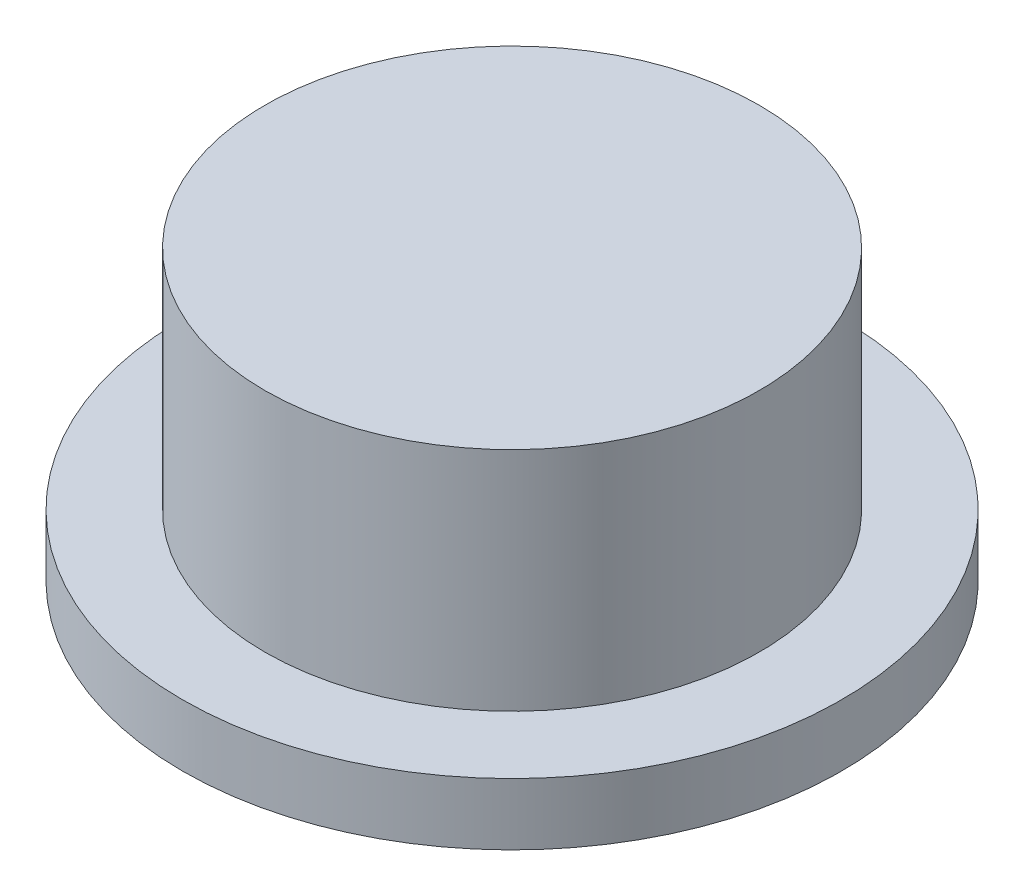
from build123d import *


with BuildPart() as part:
    # Sketch1 → Revolve1 (revolve)
    with BuildSketch(Plane(origin=(0, 0, 0), x_dir=(0, 0, -1), z_dir=(1, 0, 0))):
        with BuildLine():
            Line((-7.881941385, -0.9375), (-16, -0.9375))
            Line((-16, -0.9375), (-16, 2.0625))
            Line((-16, 2.0625), (-12, 2.0625))
            Line((-12, 2.0625), (-12, 13.0625))
            Line((-12, 13.0625), (0, 13.0625))
            Line((0, 13.0625), (0, 0))
            Line((0, 0), (0, -7.9375))
            ThreePointArc((0, -7.9375), (-5.270792161, -5.934867838), (-7.881941385, -0.9375))
        make_face()
    revolve(axis=Axis((0, -19.657005973, 0), (0, -1, 0)))


solid = part.part
